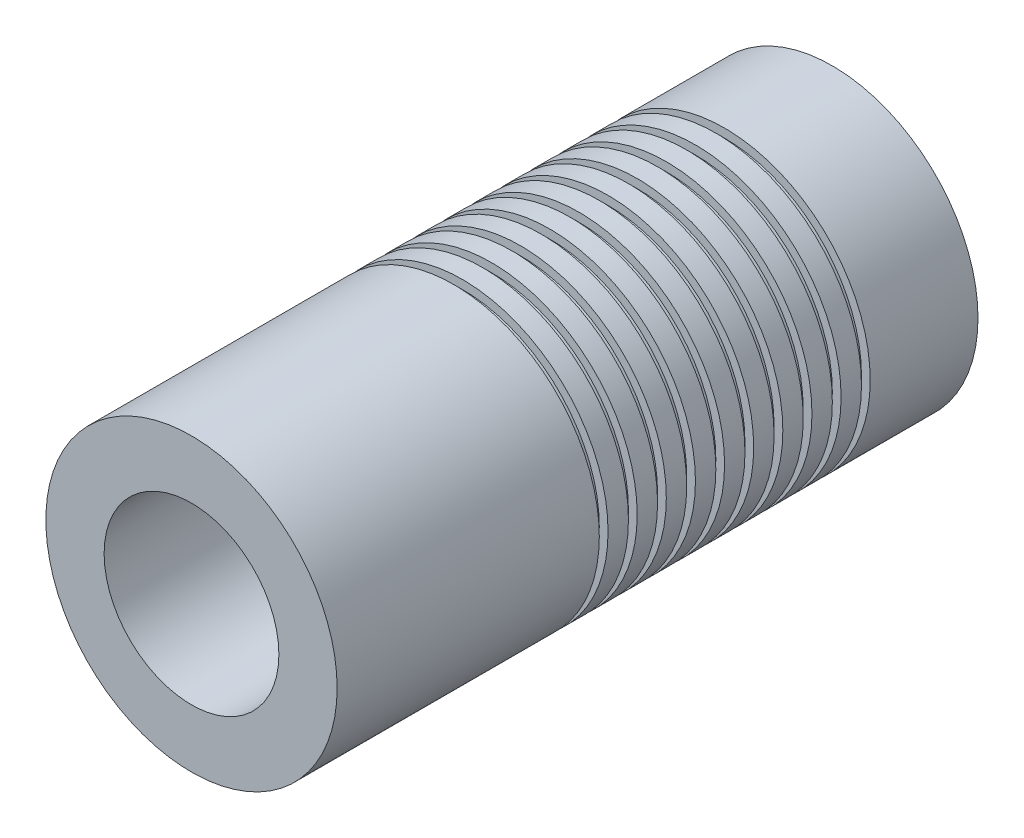
from build123d import *

# Parameters (mm, degrees)
SKETCH1_R                = 5
BOSS_EXTRUDE1_DEPTH      = 9
BOSS_EXTRUDE1_DEPTH_BACK = 13
SKETCH2_R                = 3
CUT_EXTRUDE1_DEPTH       = 5
SKETCH3_R                = 4
CUT_EXTRUDE2_DEPTH       = 5
SKETCH5_R                = 5
SKETCH5_R_2              = 4.7
CUT_EXTRUDE3_DEPTH       = 0.3
LPATTERN1_COUNT          = 10
LPATTERN1_PITCH          = 1


with BuildPart() as part:
    # Sketch1 → Boss-Extrude1 (new body, two sides)
    with BuildSketch(Plane.XY) as boss_extrude1_sk:
        Circle(SKETCH1_R)
    extrude(amount=BOSS_EXTRUDE1_DEPTH)
    extrude(boss_extrude1_sk.sketch, amount=-BOSS_EXTRUDE1_DEPTH_BACK)

    # Sketch2 → Cut-Extrude1 (cut)
    with BuildSketch(Plane.XY.offset(9)):
        Circle(SKETCH2_R)
    extrude(amount=-CUT_EXTRUDE1_DEPTH, mode=Mode.SUBTRACT)

    # Sketch3 → Cut-Extrude2 (cut)
    with BuildSketch(Plane(origin=(0, 0, -13), x_dir=(-1, 0, 0), z_dir=(0, 0, -1))):
        Circle(SKETCH3_R)
    extrude(amount=-CUT_EXTRUDE2_DEPTH, mode=Mode.SUBTRACT)

    # Sketch5 → Cut-Extrude3 (cut)
    with BuildSketch(Plane.XY):
        Circle(SKETCH5_R)
        Circle(SKETCH5_R_2, mode=Mode.SUBTRACT)
    cut_extrude3 = extrude(amount=-CUT_EXTRUDE3_DEPTH, mode=Mode.SUBTRACT)

    # LPattern1: Cut-Extrude3 ×10
    with Locations(*[(0, 0, -i * LPATTERN1_PITCH) for i in range(1, LPATTERN1_COUNT)]):
        add(cut_extrude3, mode=Mode.SUBTRACT)


solid = part.part
